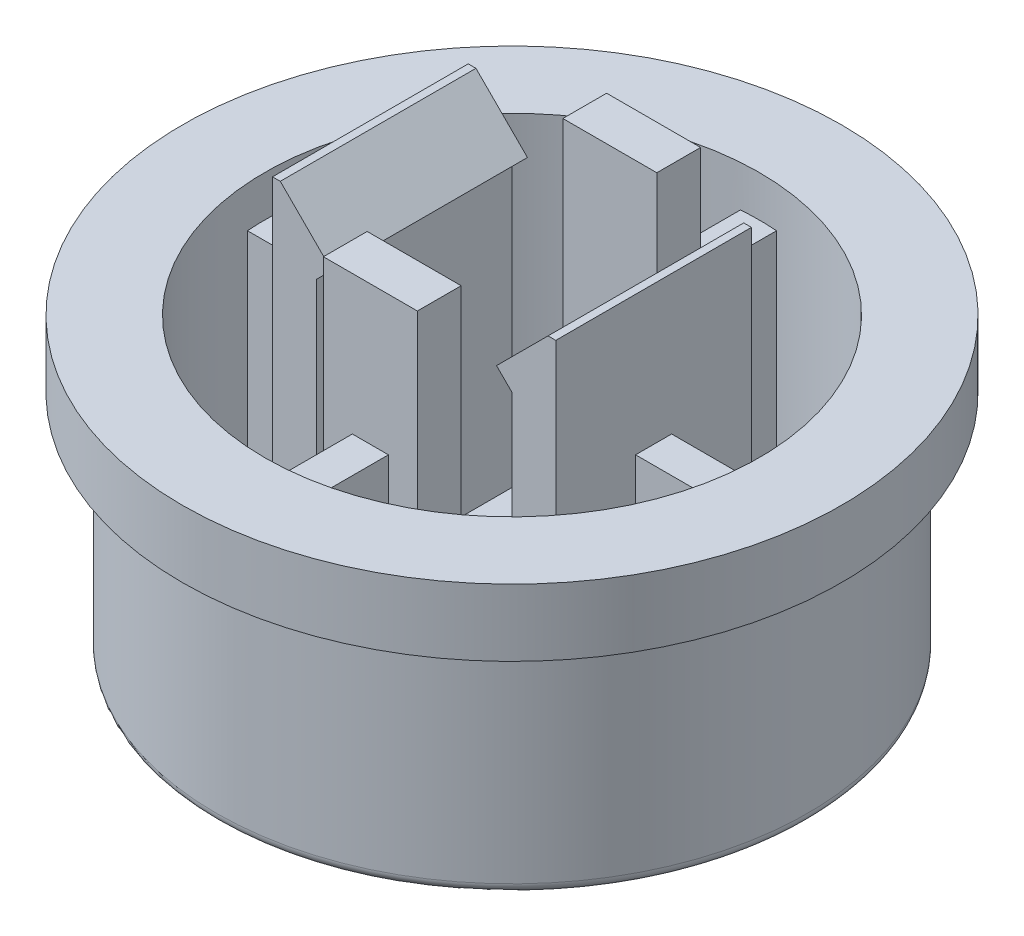
from build123d import *

# Parameters (mm, degrees)
SKETCH_1_R          = 5.75
EXTRUDE_1_DEPTH     = 0.9
SKETCH_2_R          = 5.75
SKETCH_2_R_2        = 4.8
EXTRUDE_2_DEPTH     = 3.5
SKETCH_3_R          = 6.4
SKETCH_3_R_2        = 4.8
EXTRUDE_3_DEPTH     = 1.3
SKETCH_4_W          = 0.85
SKETCH_4_H          = 3.8
SKETCH_4_W_2        = 1.824882422
SKETCH_4_H_2        = 0.85
EXTRUDE_4_DEPTH     = 6.7
EXTRUDE_5_DEPTH     = 3.8
CUT_EXTRUDE_1_REACH = 10.3
EXTRUDE_6_DEPTH     = 4
FILLET1_R           = 0.2


with BuildPart() as part:
    # Эскиз1 → Бобышка-Вытянуть1 (new body)
    with BuildSketch(Plane(origin=(0, 0, 0), x_dir=(1, 0, 0), z_dir=(0, 1, 0))):
        Circle(SKETCH_1_R)
    extrude(amount=EXTRUDE_1_DEPTH)

    # Эскиз2 → Бобышка-Вытянуть2 (add)
    with BuildSketch(Plane(origin=(0, 0.9, 0), x_dir=(1, 0, 0), z_dir=(0, 1, 0))):
        Circle(SKETCH_2_R)
        Circle(SKETCH_2_R_2, mode=Mode.SUBTRACT)
    extrude(amount=EXTRUDE_2_DEPTH)

    # Эскиз3 → Бобышка-Вытянуть3 (add)
    with BuildSketch(Plane(origin=(0, 4.4, 0), x_dir=(1, 0, 0), z_dir=(0, 1, 0))):
        Circle(SKETCH_3_R)
        Circle(SKETCH_3_R_2, mode=Mode.SUBTRACT)
    extrude(amount=EXTRUDE_3_DEPTH)

    # Эскиз4 → Бобышка-Вытянуть4 (add)
    with BuildSketch(Plane(origin=(0, 0.9, 0), x_dir=(1, 0, 0), z_dir=(0, 1, 0))):
        with Locations((-2.325, 0)):
            Rectangle(SKETCH_4_W, SKETCH_4_H)
        with Locations((2.325, 0)):
            Rectangle(SKETCH_4_W, SKETCH_4_H)
        with Locations((0, 2.325)):
            Rectangle(SKETCH_4_W_2, SKETCH_4_H_2)
        with Locations((0, -2.325)):
            Rectangle(SKETCH_4_W_2, SKETCH_4_H_2)
    extrude(amount=EXTRUDE_4_DEPTH)

    # Эскиз5 → Бобышка-Вытянуть5 (add)
    with BuildSketch(Plane(origin=(0, 0, -1.9), x_dir=(-1, 0, 0), z_dir=(0, 0, -1))):
        Polygon((1.9, 6.3), (1.6, 6.6), (2.6, 7.6), align=None)
        Polygon((-1.9, 6.3), (-1.6, 6.6), (-2.6, 7.6), align=None)
    extrude(amount=-EXTRUDE_5_DEPTH)

    # Эскиз6 → Вырез-Вытянуть1 (cut, up to next)
    with BuildSketch(Plane(origin=(0, 0, -1.9), x_dir=(-1, 0, 0), z_dir=(0, 0, -1)), mode=Mode.PRIVATE) as cut_extrude_1_sk1:
        Polygon((1.9, 6.9), (2.6, 7.6), (1.9, 7.6), align=None)
    cut_extrude_1_tool1 = extrude(cut_extrude_1_sk1.sketch, amount=-CUT_EXTRUDE_1_REACH, mode=Mode.PRIVATE) & part.part
    add(cut_extrude_1_tool1.solids().sort_by_distance((-2.133333, 7.366667, -1.9))[0], mode=Mode.SUBTRACT)
    # Эскиз6 → Вырез-Вытянуть1 (cut, up to next)
    with BuildSketch(Plane(origin=(0, 0, -1.9), x_dir=(-1, 0, 0), z_dir=(0, 0, -1)), mode=Mode.PRIVATE) as cut_extrude_1_sk2:
        Polygon((-1.9, 6.9), (-2.6, 7.6), (-1.9, 7.6), align=None)
    cut_extrude_1_tool2 = extrude(cut_extrude_1_sk2.sketch, amount=-CUT_EXTRUDE_1_REACH, mode=Mode.PRIVATE) & part.part
    add(cut_extrude_1_tool2.solids().sort_by_distance((2.133333, 7.366667, -1.9))[0], mode=Mode.SUBTRACT)

    # Эскиз7 → Бобышка-Вытянуть6 (add)
    with BuildSketch(Plane(origin=(0, 0.9, 0), x_dir=(1, 0, 0), z_dir=(0, 1, 0))):
        with BuildLine():
            Line((-0.35, -2.75), (0.35, -2.75))
            Line((0.35, -2.75), (0.35, -4.787222577))
            ThreePointArc((0.35, -4.787222577), (0, -4.8), (-0.35, -4.787222577))
            Line((-0.35, -4.787222577), (-0.35, -2.75))
        make_face()
        with BuildLine():
            Line((4.787222577, -0.35), (2.75, -0.35))
            Line((2.75, -0.35), (2.75, 0.35))
            Line((2.75, 0.35), (4.787222577, 0.35))
            ThreePointArc((4.787222577, 0.35), (4.8, 0), (4.787222577, -0.35))
        make_face()
        with BuildLine():
            Line((0.35, 2.75), (0.35, 4.787222577))
            ThreePointArc((0.35, 4.787222577), (0, 4.8), (-0.35, 4.787222577))
            Line((-0.35, 4.787222577), (-0.35, 2.75))
            Line((-0.35, 2.75), (0.35, 2.75))
        make_face()
        with BuildLine():
            Line((-2.75, -0.35), (-4.787222577, -0.35))
            ThreePointArc((-4.787222577, -0.35), (-4.8, 0), (-4.787222577, 0.35))
            Line((-4.787222577, 0.35), (-2.75, 0.35))
            Line((-2.75, 0.35), (-2.75, -0.35))
        make_face()
    extrude(amount=EXTRUDE_6_DEPTH)

    # Fillet1
    fillet1_edges = [part.edges().sort_by_distance(p)[0] for p in [
        (-5.75, 0, 0),
    ]]
    fillet(fillet1_edges, radius=FILLET1_R)


solid = part.part
